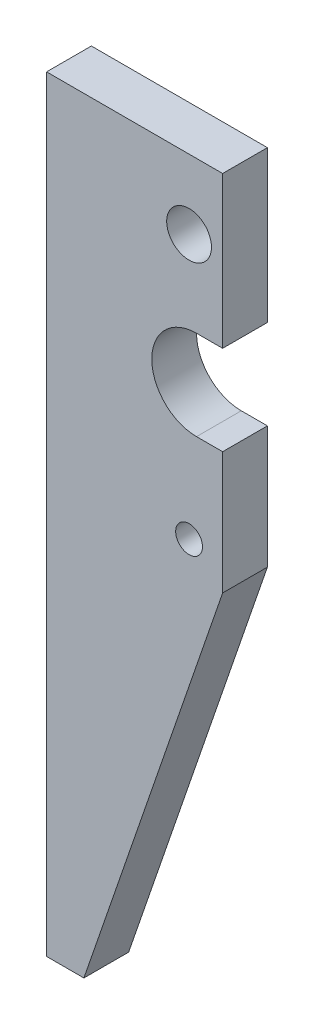
from build123d import *

# Parameters (mm, degrees)
MODEL_R                  = 1.8
MODEL_R_2                = 3
RESSALTO_EXTRUS_O1_DEPTH = 6


with BuildPart() as part:
    # Model → Ressalto-extrusão1 (new body)
    with BuildSketch(Plane.XY):
        with BuildLine():
            Line((57.173673193, 108.36959926), (33.573673193, 108.36959926))
            Line((33.573673193, 108.36959926), (33.573673193, 5.671329379))
            Line((33.573673193, 5.671329379), (38.573673193, 5.671329379))
            Line((38.573673193, 5.671329379), (57.173673193, 59.671329379))
            Line((57.173673193, 59.671329379), (57.173673193, 76.071329379))
            Line((57.173673193, 76.071329379), (53.673673193, 76.071329379))
            ThreePointArc((53.673673193, 76.071329379), (47.673673193, 82.071329379), (53.673673193, 88.071329379))
            Line((53.673673193, 88.071329379), (57.173673193, 88.071329379))
            Line((57.173673193, 88.071329379), (57.173673193, 108.36959926))
        make_face()
        with Locations((52.673673193, 63.671329379)):
            Circle(MODEL_R, mode=Mode.SUBTRACT)
        with Locations((52.673673193, 99.058930778)):
            Circle(MODEL_R_2, mode=Mode.SUBTRACT)
    extrude(amount=RESSALTO_EXTRUS_O1_DEPTH)


solid = part.part
